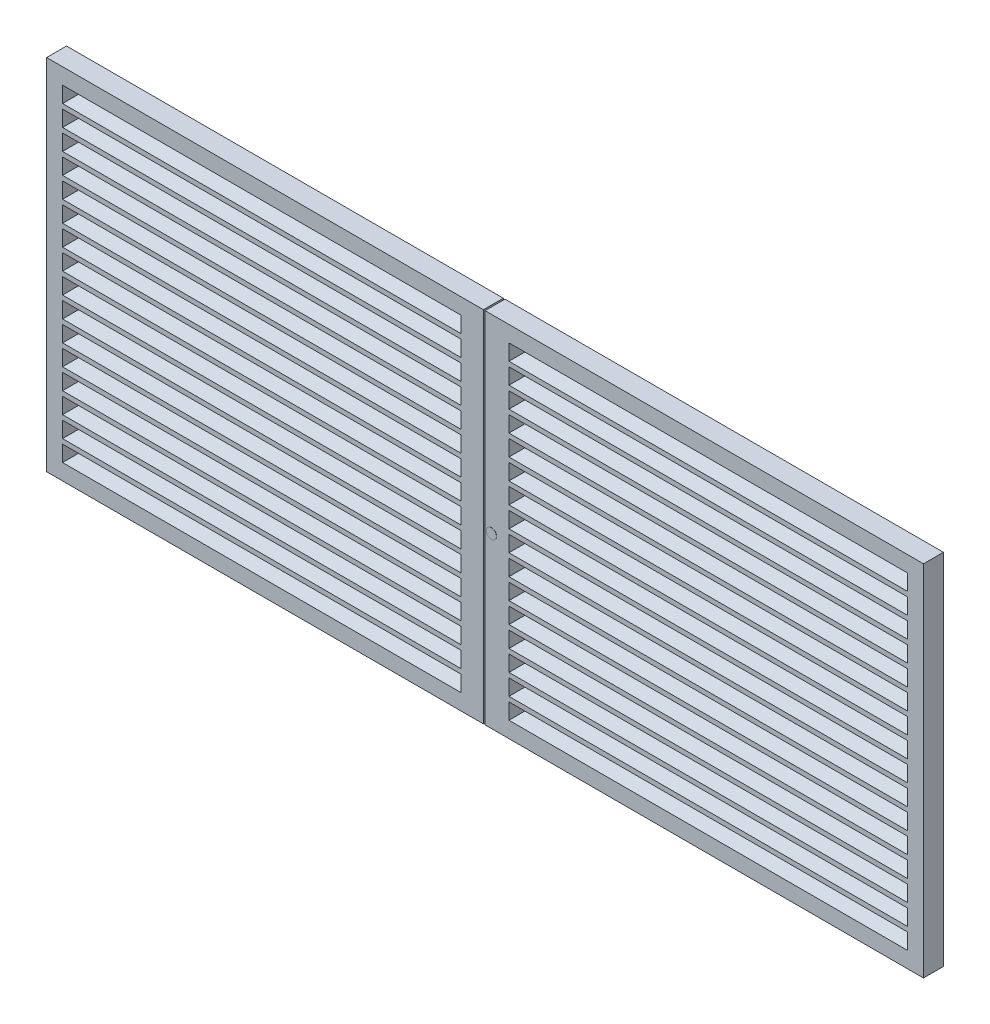
from build123d import *

# Parameters (mm, degrees)
CROQUIS1_W              = 11000
CROQUIS1_H              = 4500
SALIENTE_EXTRUIR1_DEPTH = 250
CROQUIS2_W              = 5000
CROQUIS2_H              = 200
CORTAR_EXTRUIR1_DEPTH   = 250
CORTAR_EXTRUIR1_TAPER   = 20
MATRIZL1_COUNT          = 16
MATRIZL1_PITCH          = 260
CROQUIS3_R              = 64.149560556
SALIENTE_EXTRUIR2_DEPTH = 2
CROQUIS4_W              = 20.5083018
CROQUIS4_H              = 4500
CORTAR_EXTRUIR2_DEPTH   = 250


with BuildPart() as part:
    # Croquis1 → Saliente-Extruir1 (new body)
    with BuildSketch(Plane.XY):
        with Locations((5500, 2250)):
            Rectangle(CROQUIS1_W, CROQUIS1_H)
    extrude(amount=SALIENTE_EXTRUIR1_DEPTH)

    # Croquis2 → Cortar-Extruir1 (cut)
    with BuildSketch(Plane.XY.offset(250)):
        with Locations((2700, 4200)):
            Rectangle(CROQUIS2_W, CROQUIS2_H)
        with Locations((8300, 4200)):
            Rectangle(CROQUIS2_W, CROQUIS2_H)
    cortar_extruir1 = extrude(amount=-CORTAR_EXTRUIR1_DEPTH, taper=CORTAR_EXTRUIR1_TAPER, mode=Mode.SUBTRACT)

    # MatrizL1: Cortar-Extruir1 ×16
    with Locations(*[(0, -i * MATRIZL1_PITCH, 0) for i in range(1, MATRIZL1_COUNT)]):
        add(cortar_extruir1, mode=Mode.SUBTRACT)

    # Croquis3 → Saliente-Extruir2 (add)
    with BuildSketch(Plane.XY.offset(250)):
        with Locations((5580.843384427, 2120)):
            Circle(CROQUIS3_R)
    extrude(amount=SALIENTE_EXTRUIR2_DEPTH)

    # Croquis4 → Cortar-Extruir2 (cut)
    with BuildSketch(Plane.XY.offset(250)):
        with Locations((5489.7458491, 2250)):
            Rectangle(CROQUIS4_W, CROQUIS4_H)
    extrude(amount=-CORTAR_EXTRUIR2_DEPTH, mode=Mode.SUBTRACT)


solid = part.part
